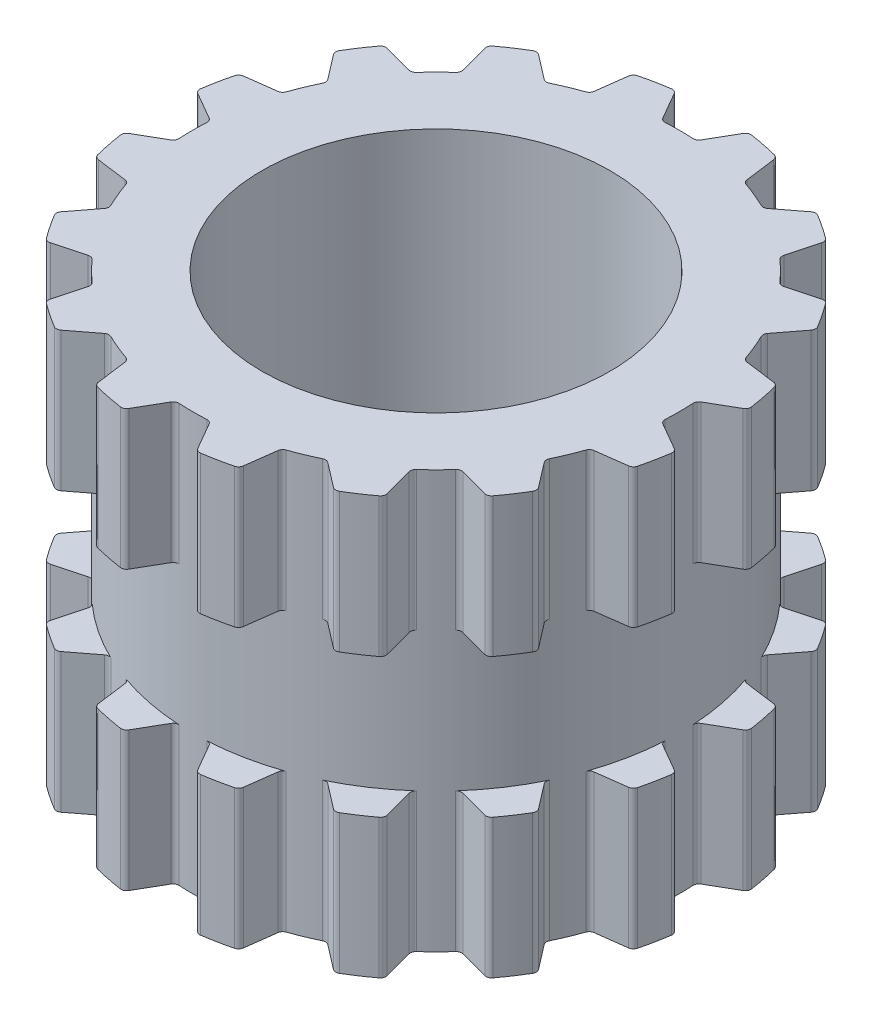
from build123d import *
from build123d.topology import SkipClean

# Parameters (mm, degrees)
BODYS_W               = 2
BODYS_H               = 3
M3X0_5_TAPPED_HOLE1_D = 2.5
MIDBODYCUTS_W         = 0.25
MIDBODYCUTS_H         = 1
GROOVECUT_DEPTH       = 4.201562119
GCCP_COUNT            = 16


with BuildPart() as part:
    # BodyS → Body (revolve)
    with BuildSketch(Plane.XY, mode=Mode.PRIVATE) as body_sk:
        with Locations((1, 0)):
            Rectangle(BODYS_W, BODYS_H)
    revolve(body_sk.sketch.rotate(Axis((0, -1.5, 0), (0, 1, 0)), 90), axis=Axis((0, -1.5, 0), (0, 1, 0)))

    # M3x0.5 Tapped Hole1 (through all)
    with Locations(Plane(origin=(0, 1.5, 0), x_dir=(1, 0, 0), z_dir=(0, 1, 0))):
        with Locations((0, 0)):
            Hole(M3X0_5_TAPPED_HOLE1_D / 2)

    # MidBodyCutS → MidBodyCut (revolve, cut)
    with BuildSketch(Plane.XY, mode=Mode.PRIVATE) as midbodycut_sk:
        with Locations((1.875, 0)):
            Rectangle(MIDBODYCUTS_W, MIDBODYCUTS_H)
    revolve(midbodycut_sk.sketch.rotate(Axis((0, 5.5, 0), (0, -1, 0)), 270), axis=Axis((0, 5.5, 0), (0, -1, 0)), mode=Mode.SUBTRACT)

    # GrooveCutS → GrooveCut (cut, symmetric)
    with SkipClean():  # the faces are left unmerged after this step: merging them gives an invalid solid
        with BuildSketch(Plane(origin=(0, 0, 0), x_dir=(1, 0, 0), z_dir=(0, 1, 0))):
            with BuildLine():
                Line((0.136871074, 1.767078346), (0.247975811, 1.959517396))
                ThreePointArc((0.247975811, 1.959517396), (0.265173181, 1.975513496), (0.288384518, 1.979099384))
                ThreePointArc((0.288384518, 1.979099384), (0, 2), (-0.288384518, 1.979099384))
                ThreePointArc((-0.288384518, 1.979099384), (-0.265173181, 1.975513496), (-0.247975811, 1.959517396))
                Line((-0.247975811, 1.959517396), (-0.136871074, 1.767078346))
                ThreePointArc((-0.136871074, 1.767078346), (-0.121232286, 1.751880117), (-0.099945587, 1.747143635))
                ThreePointArc((-0.099945587, 1.747143635), (0, 1.75), (0.099945587, 1.747143635))
                ThreePointArc((0.099945587, 1.747143635), (0.121232286, 1.751880117), (0.136871074, 1.767078346))
            make_face()
        groovecut = extrude(amount=GROOVECUT_DEPTH, both=True, mode=Mode.SUBTRACT)

    # GCCP: GrooveCut ×16 about axis
    with SkipClean():  # the faces are left unmerged after this step: merging them gives an invalid solid
        gccp_axis = Axis((0, 0, 0), (0, 1, 0))
        for i in range(1, GCCP_COUNT):
            add(groovecut.rotate(gccp_axis, i * 360 / GCCP_COUNT), mode=Mode.SUBTRACT)


solid = part.part
